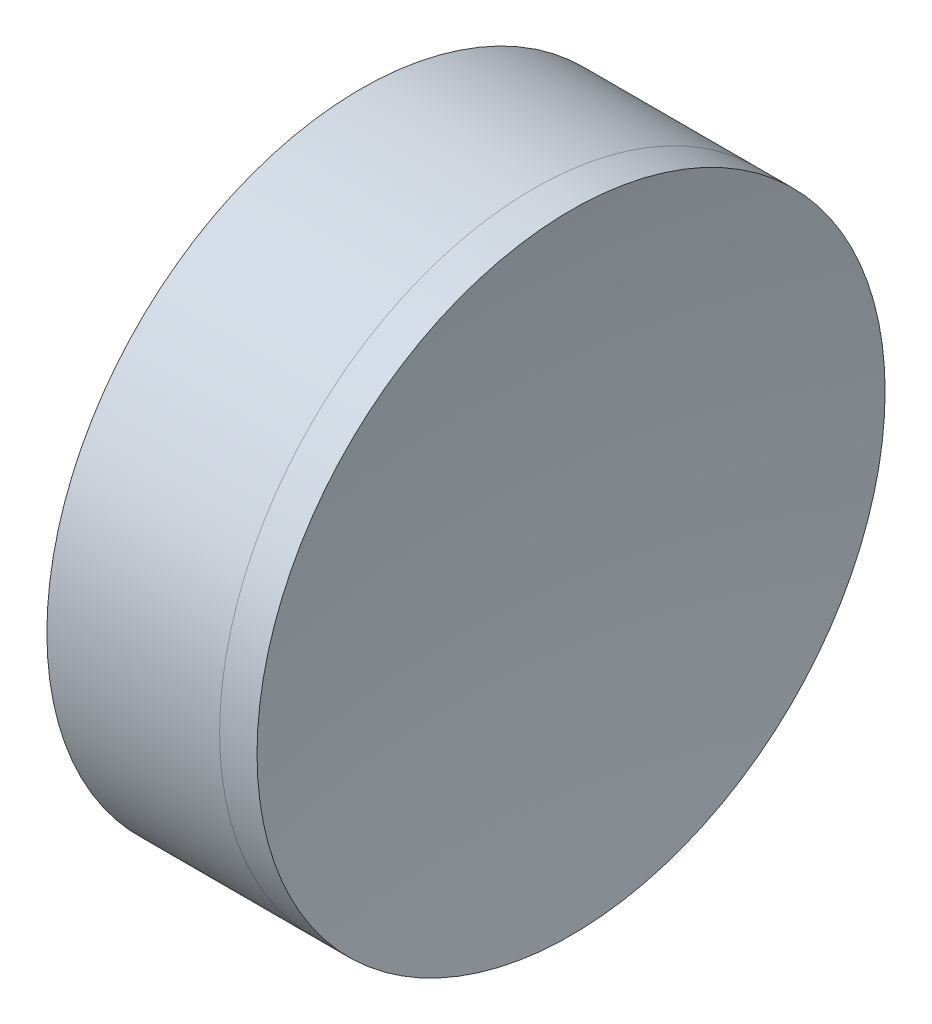
from build123d import *


with BuildPart() as part:
    # 草图1 one side → 旋转1 (revolve)
    with BuildSketch(Plane(origin=(0, 0, 0), x_dir=(1, 0, 0), z_dir=(0, 1, 0)), mode=Mode.PRIVATE) as revolve_1_sk:
        with BuildLine():
            Line((261.634531785, 20), (250.633803891, 20))
            ThreePointArc((250.633803891, 20), (253.458423549, 10.176777115), (254.410994614, 0))
            Line((254.410994614, 0), (256.410994614, 0))
            ThreePointArc((256.410994614, 0), (257.738419958, 10.335440733), (261.634531785, 20))
        make_face()
    revolve(revolve_1_sk.sketch.rotate(Axis((-0.816062176, 0, 0), (1, 0, 0)), 180), axis=Axis((-0.816062176, 0, 0), (1, 0, 0)))  # turned: the seam where the file's is


with BuildPart() as body_2:
    # 草图2 one side → 旋转3 (revolve)
    with BuildSketch(Plane(origin=(0, 0, 0), x_dir=(1, 0, 0), z_dir=(0, 1, 0))):
        with BuildLine():
            Line((264.015516295, 20), (261.634531785, 20))
            ThreePointArc((261.634531785, 20), (257.738419958, 10.335440733), (256.410994614, 0))
            Line((256.410994614, 0), (262.410994614, 0))
            ThreePointArc((262.410994614, 0), (262.812768407, 10.032129508), (264.015516295, 20))
        make_face()
    revolve(axis=Axis((250.633803891, 0, 0), (1, 0, 0)))


solid = Compound([part.part, body_2.part])
